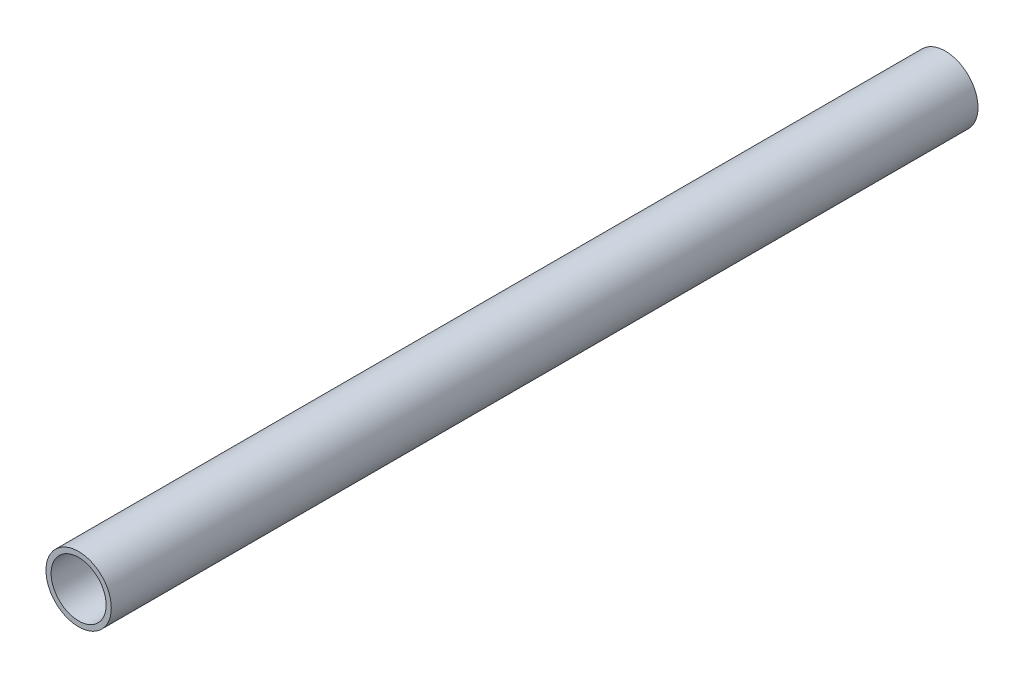
from build123d import *

# Parameters (mm, degrees)
SKETCH1_R           = 9.5
SKETCH1_R_2         = 8
BOSS_EXTRUDE1_DEPTH = 252


with BuildPart() as part:
    # Sketch1 → Boss-Extrude1 (new body)
    with BuildSketch(Plane.XY):
        Circle(SKETCH1_R)
        Circle(SKETCH1_R_2, mode=Mode.SUBTRACT)
    extrude(amount=BOSS_EXTRUDE1_DEPTH)


solid = part.part
